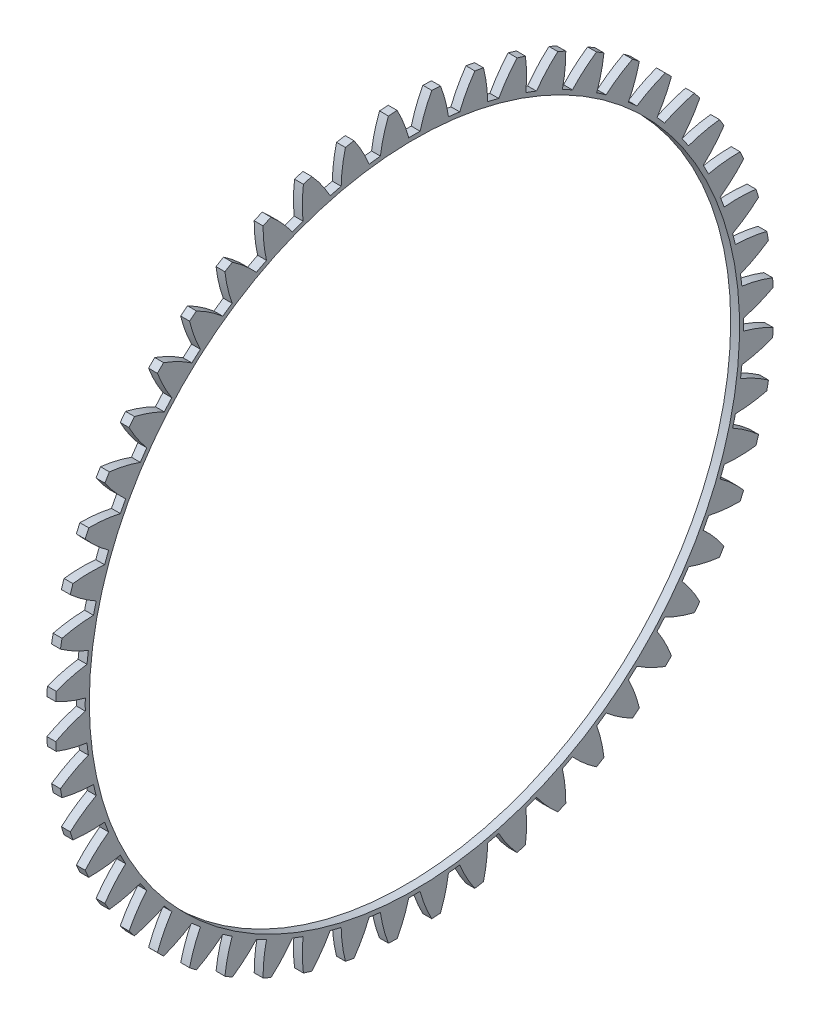
from build123d import *

# Parameters (mm, degrees)
BASPROSKE_W     = 3
BASPROSKE_H     = 121.5
TOOTHCUT_DEPTH  = 172.853134973
TEETHCUTS_COUNT = 52
TEETHCUTS_ANGLE = 353.076923077
BORSKE_R        = 110
BORE_DEPTH      = 50.0000508


with BuildPart() as part:
    # BasProSke → Base-Revolve (revolve)
    with BuildSketch(Plane(origin=(0, 0, 0), x_dir=(1, 0, 0), z_dir=(0, 1, 0)), mode=Mode.PRIVATE) as base_revolve_sk:
        with Locations((1.5, 60.75)):
            Rectangle(BASPROSKE_W, BASPROSKE_H)
    revolve(base_revolve_sk.sketch.rotate(Axis((-10, 0, 0), (1, 0, 0)), 180), axis=Axis((-10, 0, 0), (1, 0, 0)))

    # TooCutSke → ToothCut (cut, through all)
    with BuildSketch(Plane(origin=(0, 0, 0), x_dir=(0, 0, -1), z_dir=(1, 0, 0))):
        with BuildLine():
            ThreePointArc((1.922680279, 111.357402882), (0, 111.374), (-1.922680279, 111.357402882))
            ThreePointArc((-1.922680279, 111.357402882), (-3.609245468, 116.484498163), (-5.874910396, 121.383311345))
            ThreePointArc((-5.874910396, 121.383311345), (0, 121.5254), (5.874910396, 121.383311345))
            ThreePointArc((5.874910396, 121.383311345), (3.609245468, 116.484498163), (1.922680279, 111.357402882))
        make_face()
    toothcut = extrude(amount=TOOTHCUT_DEPTH, mode=Mode.SUBTRACT)

    # TeethCuts: ToothCut ×52 about axis
    teethcuts_axis = Axis((-10, 0, 0), (1, 0, 0))
    for i in range(1, TEETHCUTS_COUNT):
        add(toothcut.rotate(teethcuts_axis, i * TEETHCUTS_ANGLE / (TEETHCUTS_COUNT - 1)), mode=Mode.SUBTRACT)

    # BorSke → Bore (cut, symmetric)
    with BuildSketch(Plane(origin=(0, 0, 0), x_dir=(0, 0, -1), z_dir=(1, 0, 0))):
        with Locations(Location((0, 0, 0), (0, 0, 180))):
            Circle(BORSKE_R)
    extrude(amount=BORE_DEPTH, both=True, mode=Mode.SUBTRACT)


solid = part.part
